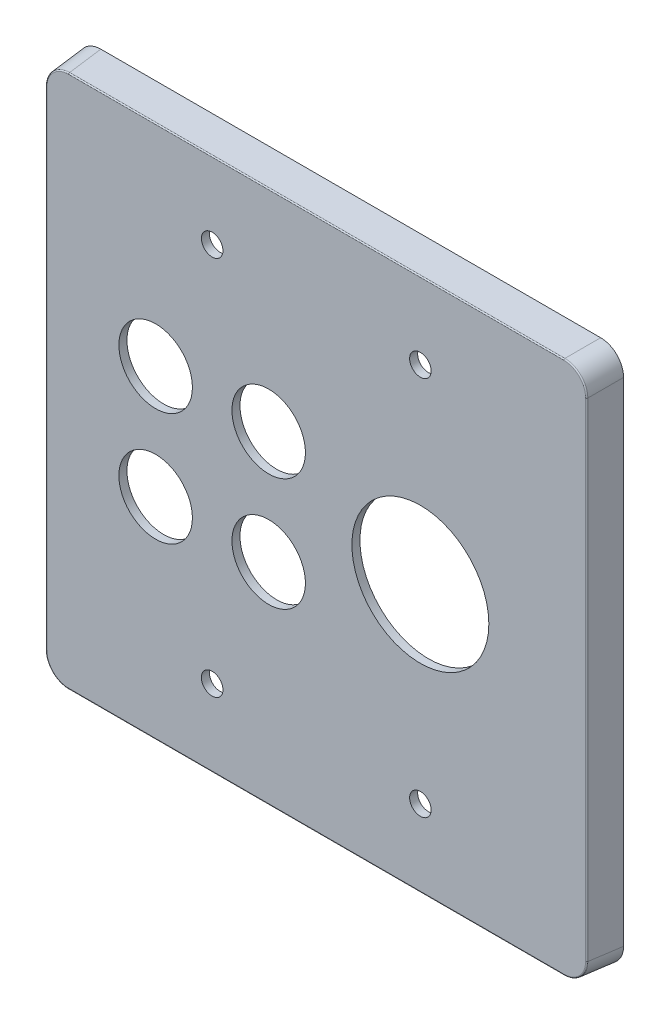
from build123d import *

# Parameters (mm, degrees)
SKETCH1_W           = 120.65
SKETCH1_H           = 119.0625
BOSS_EXTRUDE1_DEPTH = 7.62
BOSS_EXTRUDE1_TAPER = 4
FILLET1_R           = 5.08
FILLET2_R           = 0.254
SHELL1_T            = -1.778
SKETCH5_R           = 2.38125
CUT_EXTRUDE1_DEPTH  = 8.6200001
SKETCH6_R           = 15.13967
SKETCH6_R_2         = 8.128
CUT_EXTRUDE2_DEPTH  = 8.6200001


with BuildPart() as part:
    # Sketch1 → Boss-Extrude1 (new body)
    with BuildSketch(Plane.XY):
        Rectangle(SKETCH1_W, SKETCH1_H)
    extrude(amount=BOSS_EXTRUDE1_DEPTH, taper=BOSS_EXTRUDE1_TAPER)

    # Fillet1
    fillet1_edges = [part.edges().sort_by_distance(p)[0] for p in [
        (-60.058578385, 59.264828385, 3.810006606),
        (60.058578385, 59.264828385, 3.810006606),
        (60.058578385, -59.264828385, 3.810006606),
        (-60.058578846, -59.264828846, 3.81),
    ]]
    fillet(fillet1_edges, radius=FILLET1_R)

    # Fillet2
    fillet2_edges = [part.edges().sort_by_distance(p)[0] for p in [
        (0, -58.998407693, 7.62),
        (-59.792157693, 0, 7.62),
        (59.792157693, 0, 7.62),
        (0, 58.998407693, 7.62),
        (-58.30937708, 57.51562708, 7.62),
        (58.30937708, 57.51562708, 7.62),
        (58.30937708, -57.51562708, 7.62),
        (-58.30937708, -57.51562708, 7.62),
    ]]
    fillet(fillet2_edges, radius=FILLET2_R)

    # Shell1
    shell1_openings = [part.faces().sort_by_distance(p)[0] for p in [
        (0, 0, 0),
    ]]
    offset(amount=SHELL1_T, openings=shell1_openings, kind=Kind.INTERSECTION)

    # Sketch5 → Cut-Extrude1 (cut, through all)
    with BuildSketch(Plane.XY.offset(7.62)):
        with Locations((-23.01875, 42.037)):
            Circle(SKETCH5_R)
        with Locations((-23.01875, -42.037)):
            Circle(SKETCH5_R)
        with Locations((23.01875, -42.037)):
            Circle(SKETCH5_R)
        with Locations((23.01875, 42.037)):
            Circle(SKETCH5_R)
    extrude(amount=-CUT_EXTRUDE1_DEPTH, mode=Mode.SUBTRACT)

    # Sketch6 → Cut-Extrude2 (cut, through all)
    with BuildSketch(Plane.XY.offset(7.62)):
        with Locations((23.01875, 0)):
            Circle(SKETCH6_R)
        with Locations((-35.51555, 12.4968)):
            Circle(SKETCH6_R_2)
        with Locations((-10.52195, 12.4968)):
            Circle(SKETCH6_R_2)
        with Locations((-10.52195, -12.4968)):
            Circle(SKETCH6_R_2)
        with Locations((-35.51555, -12.4968)):
            Circle(SKETCH6_R_2)
    extrude(amount=-CUT_EXTRUDE2_DEPTH, mode=Mode.SUBTRACT)


solid = part.part
